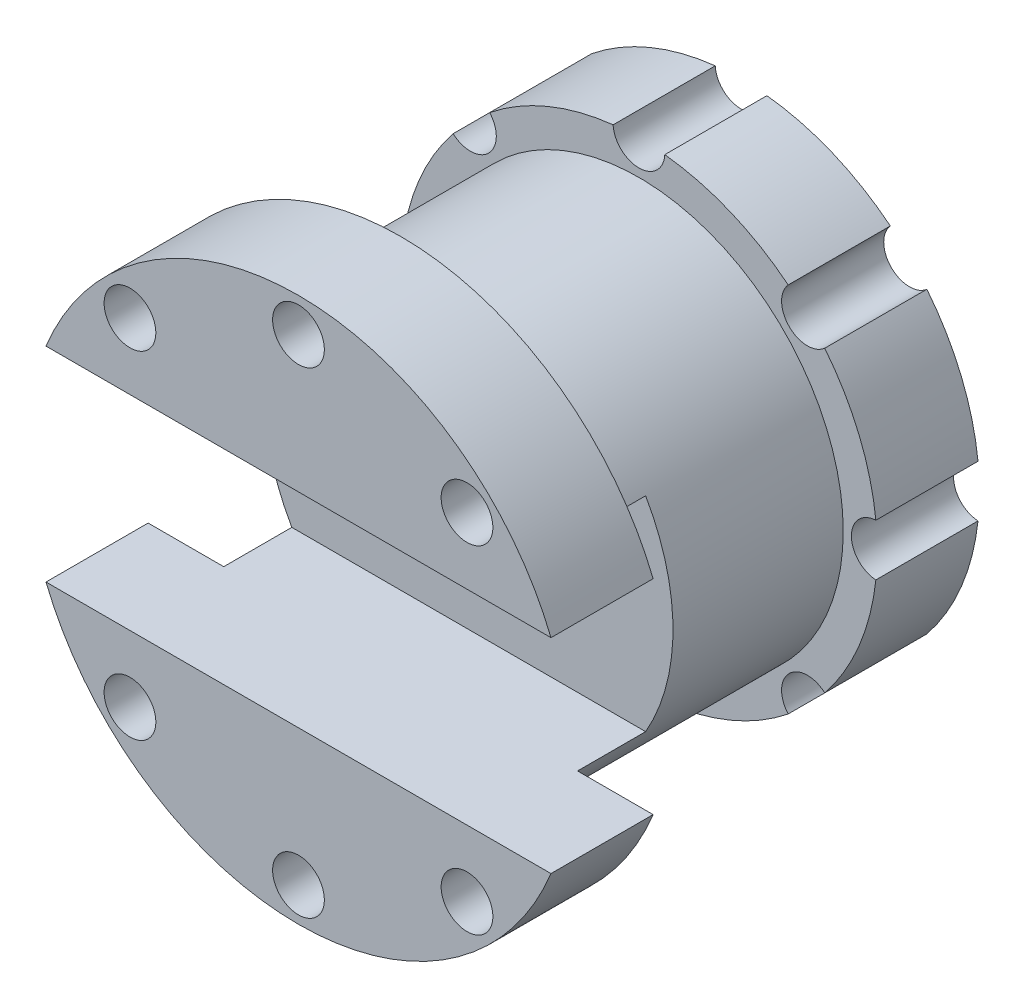
from build123d import *

# Parameters (mm, degrees)
SKETCH1_R           = 38.1
SKETCH1_R_2         = 12.7
BOSS_EXTRUDE1_DEPTH = 63.5
SKETCH1_3_R         = 38.1
BOSS_EXTRUDE2_DEPTH = 19.05
SKETCH2_R           = 4.826
BOSS_EXTRUDE3_DEPTH = 19.05
CUT_EXTRUDE1_START  = -12.7
SKETCH2_3_R         = 12.7
CUT_EXTRUDE1_DEPTH  = 12.7


with BuildPart() as part:
    # Sketch1 → Boss-Extrude1 (new body)
    with BuildSketch(Plane.XY):
        Circle(SKETCH1_R)
        Circle(SKETCH1_R_2, mode=Mode.SUBTRACT)
    extrude(amount=BOSS_EXTRUDE1_DEPTH)

    # Sketch1_3 → Boss-Extrude2 (add)
    with BuildSketch(Plane.XY):
        with BuildLine():
            ThreePointArc((44.188017143, -4.81888379), (39.624, 0), (44.188017143, 4.81888379))
            ThreePointArc((44.188017143, 4.81888379), (41.06644522, 17.010278569), (34.653111975, 27.838181163))
            ThreePointArc((34.653111975, 27.838181163), (28.018399098, 28.018399098), (27.838181163, 34.653111975))
            ThreePointArc((27.838181163, 34.653111975), (17.010278569, 41.06644522), (4.81888379, 44.188017143))
            ThreePointArc((4.81888379, 44.188017143), (0, 39.624), (-4.81888379, 44.188017143))
            ThreePointArc((-4.81888379, 44.188017143), (-17.010278569, 41.06644522), (-27.838181163, 34.653111975))
            ThreePointArc((-27.838181163, 34.653111975), (-26.923750994, 33.155980792), (-26.604896424, 31.430896424))
            ThreePointArc((-26.604896424, 31.430896424), (-29.463682181, 27.024044472), (-34.653111975, 27.838181163))
            ThreePointArc((-34.653111975, 27.838181163), (-41.06644522, 17.010278569), (-44.188017143, 4.81888379))
            ThreePointArc((-44.188017143, 4.81888379), (-40.946101795, 3.318580022), (-39.624, 0))
            ThreePointArc((-39.624, 0), (-40.946101795, -3.318580023), (-44.188017143, -4.81888379))
            ThreePointArc((-44.188017143, -4.81888379), (-41.06644522, -17.010278569), (-34.653111975, -27.838181163))
            ThreePointArc((-34.653111975, -27.838181163), (-29.463682181, -27.024044472), (-26.604896424, -31.430896424))
            ThreePointArc((-26.604896424, -31.430896424), (-26.923750994, -33.155980792), (-27.838181163, -34.653111975))
            ThreePointArc((-27.838181163, -34.653111975), (-17.010278569, -41.06644522), (-4.81888379, -44.188017143))
            ThreePointArc((-4.81888379, -44.188017143), (0, -39.624), (4.81888379, -44.188017143))
            ThreePointArc((4.81888379, -44.188017143), (17.010278569, -41.06644522), (27.838181163, -34.653111975))
            ThreePointArc((27.838181163, -34.653111975), (28.018399098, -28.018399098), (34.653111975, -27.838181163))
            ThreePointArc((34.653111975, -27.838181163), (41.06644522, -17.010278569), (44.188017143, -4.81888379))
        make_face()
        Circle(SKETCH1_3_R, mode=Mode.SUBTRACT)
    extrude(amount=BOSS_EXTRUDE2_DEPTH)

    # Sketch2 → Boss-Extrude3 (add)
    # profile 1 of 2: a face of its own
    with BuildSketch(Plane.XY.offset(63.5)):
        with BuildLine():
            ThreePointArc((47.092860393, 19.05), (0, 50.8), (-47.092860393, 19.05))
            Line((-47.092860393, 19.05), (47.092860393, 19.05))
        make_face()
        with Locations((-31.430896424, 31.430896424)):
            Circle(SKETCH2_R, mode=Mode.SUBTRACT)
        with Locations((0, 44.45)):
            Circle(SKETCH2_R, mode=Mode.SUBTRACT)
        with Locations((31.430896424, 31.430896424)):
            Circle(SKETCH2_R, mode=Mode.SUBTRACT)
    # profile 2 of 2: a face of its own
    with BuildSketch(Plane.XY.offset(63.5)):
        with BuildLine():
            Line((47.092860393, -19.05), (-47.092860393, -19.05))
            ThreePointArc((-47.092860393, -19.05), (0, -50.8), (47.092860393, -19.05))
        make_face()
        with Locations((-31.430896424, -31.430896424)):
            Circle(SKETCH2_R, mode=Mode.SUBTRACT)
        with Locations((0, -44.45)):
            Circle(SKETCH2_R, mode=Mode.SUBTRACT)
        with Locations((31.430896424, -31.430896424)):
            Circle(SKETCH2_R, mode=Mode.SUBTRACT)
    extrude(amount=BOSS_EXTRUDE3_DEPTH)

    # Sketch2_3 → Cut-Extrude1 (cut)
    with BuildSketch(Plane.XY.offset(63.5).offset(CUT_EXTRUDE1_START)):
        with BuildLine():
            Line((32.995567884, 19.05), (-32.995567884, 19.05))
            ThreePointArc((-32.995567884, 19.05), (-38.1, 0), (-32.995567884, -19.05))
            Line((-32.995567884, -19.05), (32.995567884, -19.05))
            ThreePointArc((32.995567884, -19.05), (38.1, 0), (32.995567884, 19.05))
        make_face()
        Circle(SKETCH2_3_R, mode=Mode.SUBTRACT)
    extrude(amount=CUT_EXTRUDE1_DEPTH, mode=Mode.SUBTRACT)


solid = part.part
